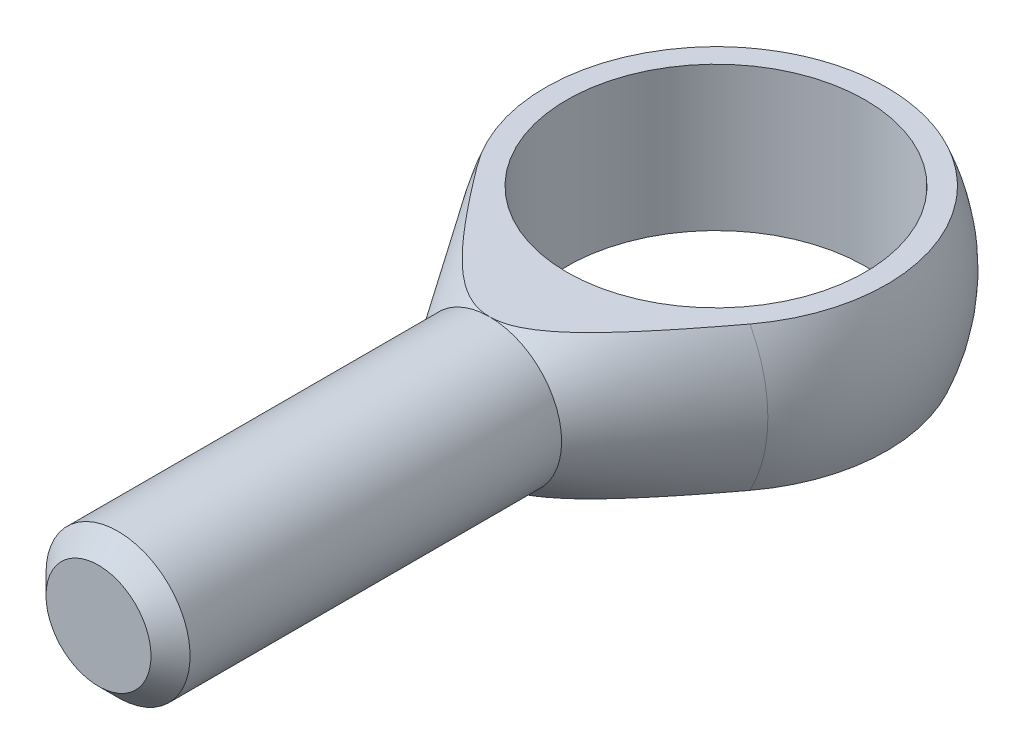
from build123d import *

# Parameters (mm, degrees)
SZKIC1_W                        = 7
SZKIC1_H                        = 38
WYTNIJ_WYCI_GNI_CIE1_DEPTH      = 19
WYTNIJ_WYCI_GNI_CIE1_DEPTH_BACK = 19
SZKIC3_R                        = 14.5
WYTNIJ_WYCI_GNI_CIE2_DEPTH      = 8
WYTNIJ_WYCI_GNI_CIE2_DEPTH_BACK = 8
SFAZOWANIE1_SIZE                = 1.9


with BuildPart() as part:
    # Szkic1 → Obrót1 (revolve)
    with BuildSketch(Plane(origin=(0, 0, 0), x_dir=(1, 0, 0), z_dir=(0, 1, 0))):
        with BuildLine():
            Line((0, 18), (0, -22))
            Line((0, -22), (7, -22))
            Line((7, -22), (14.996070523, -9.955795743))
            ThreePointArc((14.996070523, -9.955795743), (15.861972188, 8.508691927), (0, 18))
        make_face()
        with Locations((3.5, -41)):
            Rectangle(SZKIC1_W, SZKIC1_H)
    revolve(axis=Axis((0, 0, -26.043516498), (0, 0, 1)))

    # Szkic2 → Wytnij-wyciągnięcie1 (cut, two sides)
    with BuildSketch(Plane(origin=(0, 0, 0), x_dir=(0, 0, -1), z_dir=(1, 0, 0))) as wytnij_wyci_gni_cie1_sk:
        with BuildLine():
            Line((-22, 7), (16.583123952, 7))
            ThreePointArc((16.583123952, 7), (5.192750307, 17.23471335), (-9.955795743, 14.996070523))
            Line((-9.955795743, 14.996070523), (-22, 7))
        make_face()
        with BuildLine():
            Line((-22, -7), (16.583123952, -7))
            ThreePointArc((16.583123952, -7), (5.192750307, -17.23471335), (-9.955795743, -14.996070523))
            Line((-9.955795743, -14.996070523), (-22, -7))
        make_face()
    extrude(amount=WYTNIJ_WYCI_GNI_CIE1_DEPTH, mode=Mode.SUBTRACT)
    extrude(wytnij_wyci_gni_cie1_sk.sketch, amount=-WYTNIJ_WYCI_GNI_CIE1_DEPTH_BACK, mode=Mode.SUBTRACT)

    # Szkic3 → Wytnij-wyciągnięcie2 (cut, two sides)
    with BuildSketch(Plane(origin=(0, 0, 0), x_dir=(1, 0, 0), z_dir=(0, 1, 0))) as wytnij_wyci_gni_cie2_sk:
        Circle(SZKIC3_R)
    extrude(amount=WYTNIJ_WYCI_GNI_CIE2_DEPTH, mode=Mode.SUBTRACT)
    extrude(wytnij_wyci_gni_cie2_sk.sketch, amount=-WYTNIJ_WYCI_GNI_CIE2_DEPTH_BACK, mode=Mode.SUBTRACT)

    # Sfazowanie1
    sfazowanie1_edges = [part.edges().sort_by_distance(p)[0] for p in [
        (-7, 0, 60),
    ]]
    chamfer(sfazowanie1_edges, length=SFAZOWANIE1_SIZE)


solid = part.part
